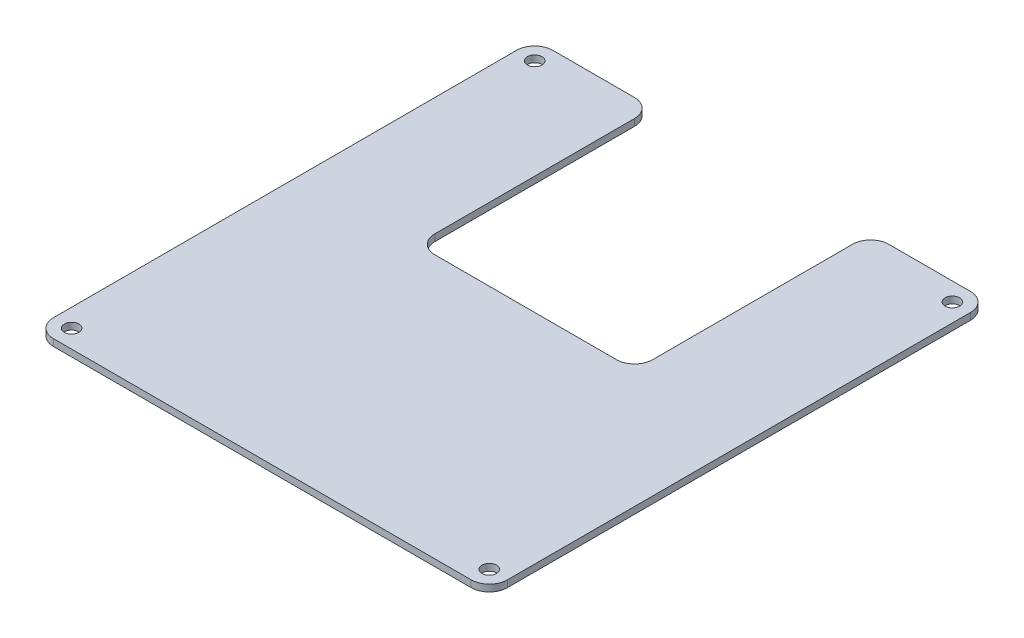
from build123d import *

# Parameters (mm, degrees)
SKETCH1_W           = 100
SKETCH1_H           = 110
BOSS_EXTRUDE1_DEPTH = 1.5
CUT_EXTRUDE1_DEPTH  = 10
FILLET1_R           = 4
SKETCH4_R           = 1.6
CUT_EXTRUDE2_DEPTH  = 10


with BuildPart() as part:
    # Sketch1 → Boss-Extrude1 (new body)
    with BuildSketch(Plane(origin=(0, 0, 0), x_dir=(1, 0, 0), z_dir=(0, 1, 0))):
        Rectangle(SKETCH1_W, SKETCH1_H)
    extrude(amount=BOSS_EXTRUDE1_DEPTH)

    # Sketch2 → Cut-Extrude1 (cut)
    with BuildSketch(Plane(origin=(0, 0, 0), x_dir=(-1, 0, 0), z_dir=(0, -1, 0))):
        Polygon((0, 55), (-24, 55), (-24, 3), (24, 3), (24, 55), align=None)
    extrude(amount=-CUT_EXTRUDE1_DEPTH, mode=Mode.SUBTRACT)

    # Fillet1
    fillet1_edges = [part.edges().sort_by_distance(p)[0] for p in [
        (-24, 0.75, -55),
        (-24, 0.75, -3),
        (24, 0.75, -3),
        (24, 0.75, -55),
        (50, 0.75, 55),
        (-50, 0.75, 55),
        (-50, 0.75, -55),
        (50, 0.75, -55),
    ]]
    fillet(fillet1_edges, radius=FILLET1_R)

    # Sketch4 → Cut-Extrude2 (cut)
    with BuildSketch(Plane(origin=(0, 0, 0), x_dir=(-1, 0, 0), z_dir=(0, -1, 0))):
        with Locations((46, -51)):
            Circle(SKETCH4_R)
        with Locations((46, 51)):
            Circle(SKETCH4_R)
        with Locations((-46, 51)):
            Circle(SKETCH4_R)
        with Locations((-46, -51)):
            Circle(SKETCH4_R)
    extrude(amount=-CUT_EXTRUDE2_DEPTH, mode=Mode.SUBTRACT)


solid = part.part
